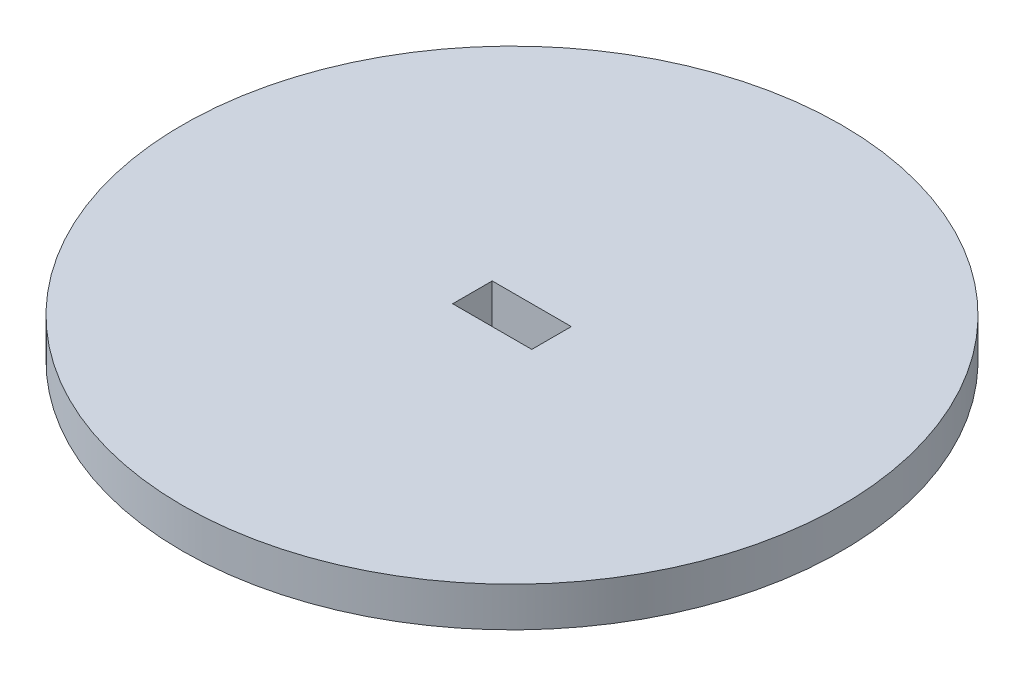
from build123d import *

# Parameters (mm, degrees)
SKETCH_1_R          = 25
EXTRUDE_1_DEPTH     = 3
SKETCH_2_W          = 6
SKETCH_2_H          = 3
CUT_EXTRUDE_2_DEPTH = 11


with BuildPart() as part:
    # 草图1 → 凸台-拉伸1 (new body)
    with BuildSketch(Plane(origin=(0, 0, 0), x_dir=(1, 0, 0), z_dir=(0, 1, 0))):
        Circle(SKETCH_1_R)
    extrude(amount=EXTRUDE_1_DEPTH)

    # 草图2 → 切除-拉伸2 (cut)
    with BuildSketch(Plane(origin=(0, 3, 0), x_dir=(1, 0, 0), z_dir=(0, 1, 0))):
        Rectangle(SKETCH_2_W, SKETCH_2_H)
    extrude(amount=-CUT_EXTRUDE_2_DEPTH, mode=Mode.SUBTRACT)


solid = part.part
